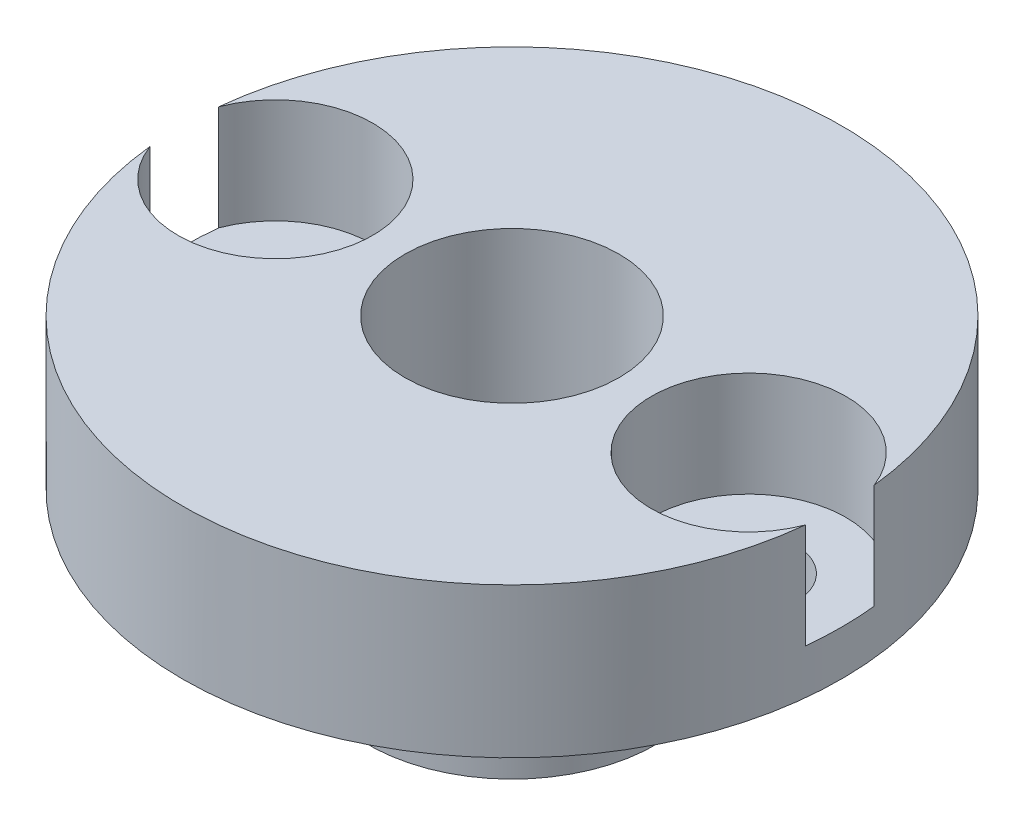
from build123d import *

# Parameters (mm, degrees)
CROQUIS1_R              = 11
SALIENTE_EXTRUIR1_DEPTH = 5
CROQUIS2_R              = 4.8
SALIENTE_EXTRUIR2_DEPTH = 5
CROQUIS3_R              = 1.6
CORTAR_EXTRUIR1_DEPTH   = 6
CROQUIS4_R              = 3.575
CORTAR_EXTRUIR2_DEPTH   = 11
CROQUIS5_R              = 3.25
CORTAR_EXTRUIR3_DEPTH   = 3.5


with BuildPart() as part:
    # Croquis1 → Saliente-Extruir1 (new body)
    with BuildSketch(Plane(origin=(0, 0, 0), x_dir=(1, 0, 0), z_dir=(0, 1, 0))):
        Circle(CROQUIS1_R)
    extrude(amount=SALIENTE_EXTRUIR1_DEPTH)

    # Croquis2 → Saliente-Extruir2 (add)
    with BuildSketch(Plane.XZ):
        Circle(CROQUIS2_R)
    extrude(amount=SALIENTE_EXTRUIR2_DEPTH)

    # Croquis3 → Cortar-Extruir1 (cut, through all)
    with BuildSketch(Plane.XZ):
        with Locations((-7.9, 0)):
            Circle(CROQUIS3_R)
        with Locations((7.9, 0)):
            Circle(CROQUIS3_R)
    extrude(amount=-CORTAR_EXTRUIR1_DEPTH, mode=Mode.SUBTRACT)

    # Croquis4 → Cortar-Extruir2 (cut, through all)
    with BuildSketch(Plane.XZ.offset(5)):
        Circle(CROQUIS4_R)
    extrude(amount=-CORTAR_EXTRUIR2_DEPTH, mode=Mode.SUBTRACT)

    # Croquis5 → Cortar-Extruir3 (cut)
    with BuildSketch(Plane(origin=(0, 5, 0), x_dir=(1, 0, 0), z_dir=(0, 1, 0))):
        with Locations((-7.9, 0)):
            Circle(CROQUIS5_R)
        with Locations((7.9, 0)):
            Circle(CROQUIS5_R)
    extrude(amount=-CORTAR_EXTRUIR3_DEPTH, mode=Mode.SUBTRACT)


solid = part.part
